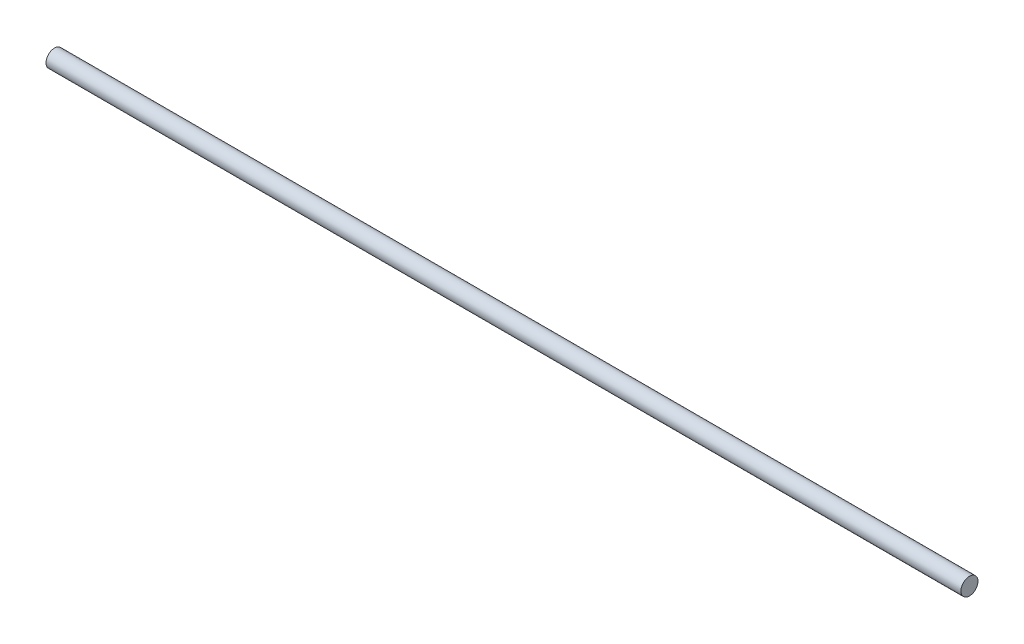
from build123d import *

# Parameters (mm, degrees)
SKETCH1_R           = 4.2
BOSS_EXTRUDE1_DEPTH = 450


with BuildPart() as part:
    # Sketch1 → Boss-Extrude1 (new body)
    with BuildSketch(Plane(origin=(0, 0, 0), x_dir=(0, 0, -1), z_dir=(1, 0, 0))):
        Circle(SKETCH1_R)
    extrude(amount=BOSS_EXTRUDE1_DEPTH)


solid = part.part
